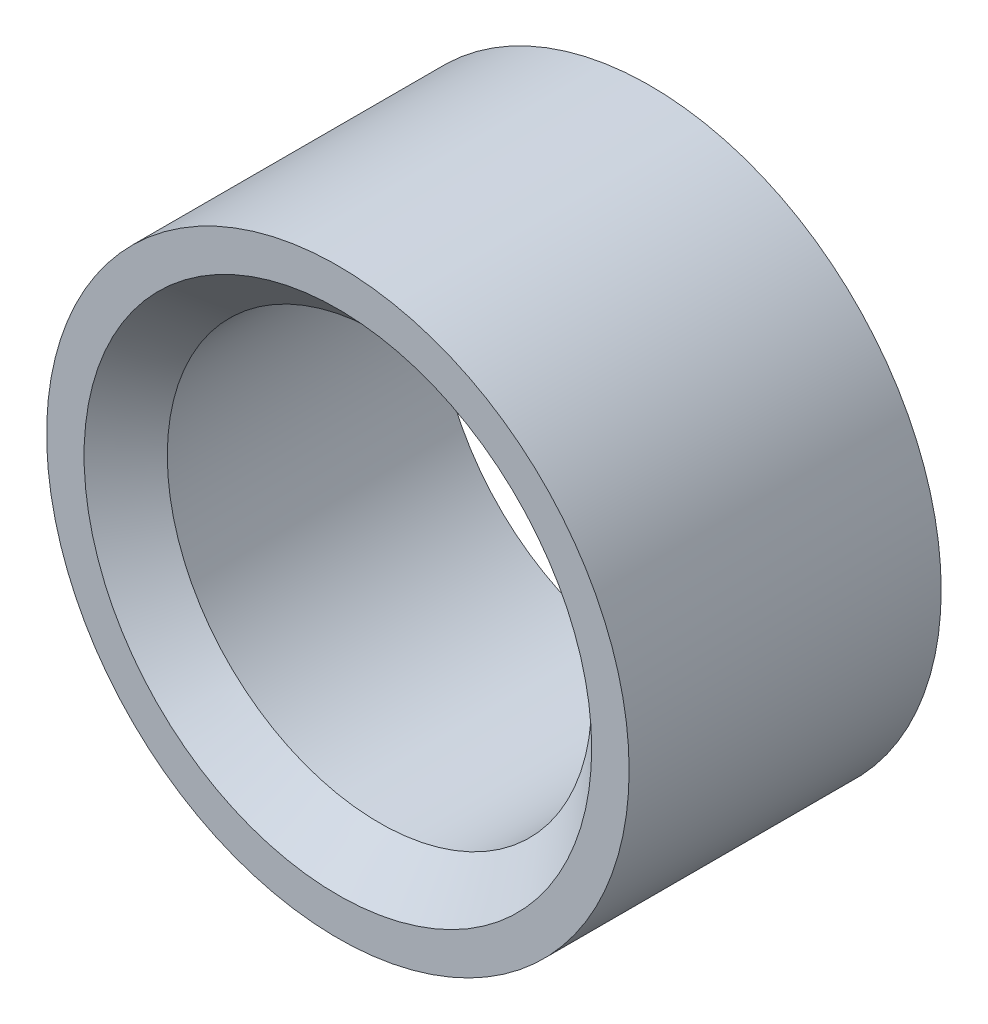
from build123d import *

# Parameters (mm, degrees)
SKETCH_1_R      = 14
SKETCH_1_R_2    = 10.2
EXTRUDE_1_DEPTH = 15
CHAMFER_1_SIZE  = 2


with BuildPart() as part:
    # 草图1 → 凸台-拉伸1 (new body)
    with BuildSketch(Plane.XY):
        Circle(SKETCH_1_R)
        Circle(SKETCH_1_R_2, mode=Mode.SUBTRACT)
    extrude(amount=EXTRUDE_1_DEPTH)

    # 倒角1
    chamfer_1_edges = [part.edges().sort_by_distance(p)[0] for p in [
        (-10.2, 0, 15),
    ]]
    chamfer(chamfer_1_edges, length=CHAMFER_1_SIZE)


solid = part.part
